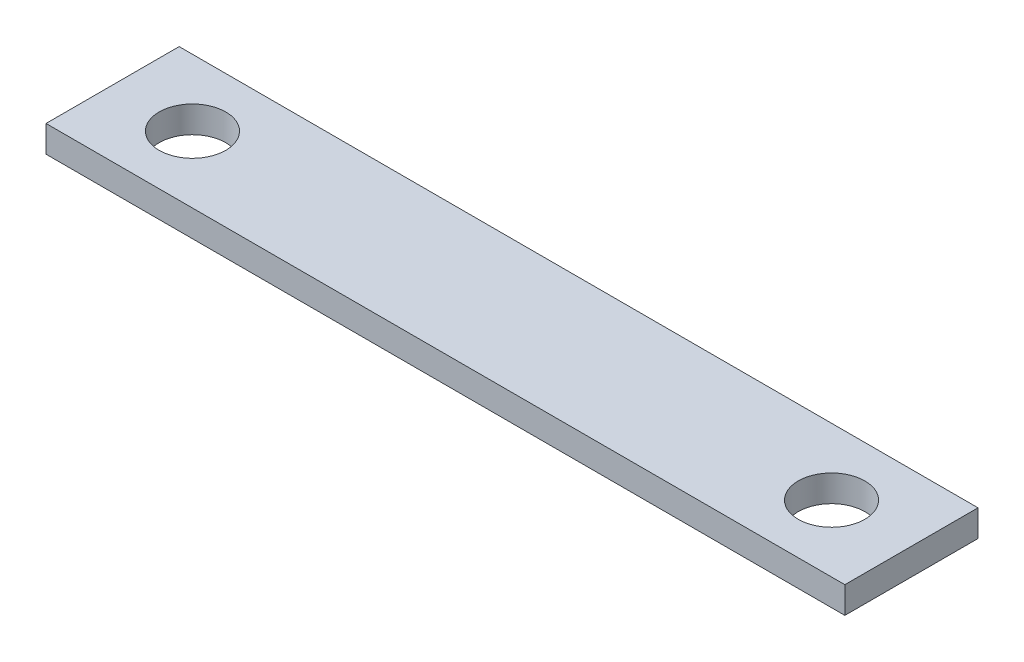
from build123d import *

# Parameters (mm, degrees)
SKETCH1_W           = 76.2
SKETCH1_H           = 12.7
SKETCH1_R           = 3.175
BOSS_EXTRUDE2_DEPTH = 2.54


with BuildPart() as part:
    # Sketch1 → Boss-Extrude2 (new body)
    with BuildSketch(Plane(origin=(0, 0, 0), x_dir=(1, 0, 0), z_dir=(0, 1, 0))):
        with Locations((38.1, 6.35)):
            Rectangle(SKETCH1_W, SKETCH1_H)
        with Locations((7.62, 6.35)):
            Circle(SKETCH1_R, mode=Mode.SUBTRACT)
        with Locations((68.58, 6.35)):
            Circle(SKETCH1_R, mode=Mode.SUBTRACT)
    extrude(amount=BOSS_EXTRUDE2_DEPTH)


solid = part.part
